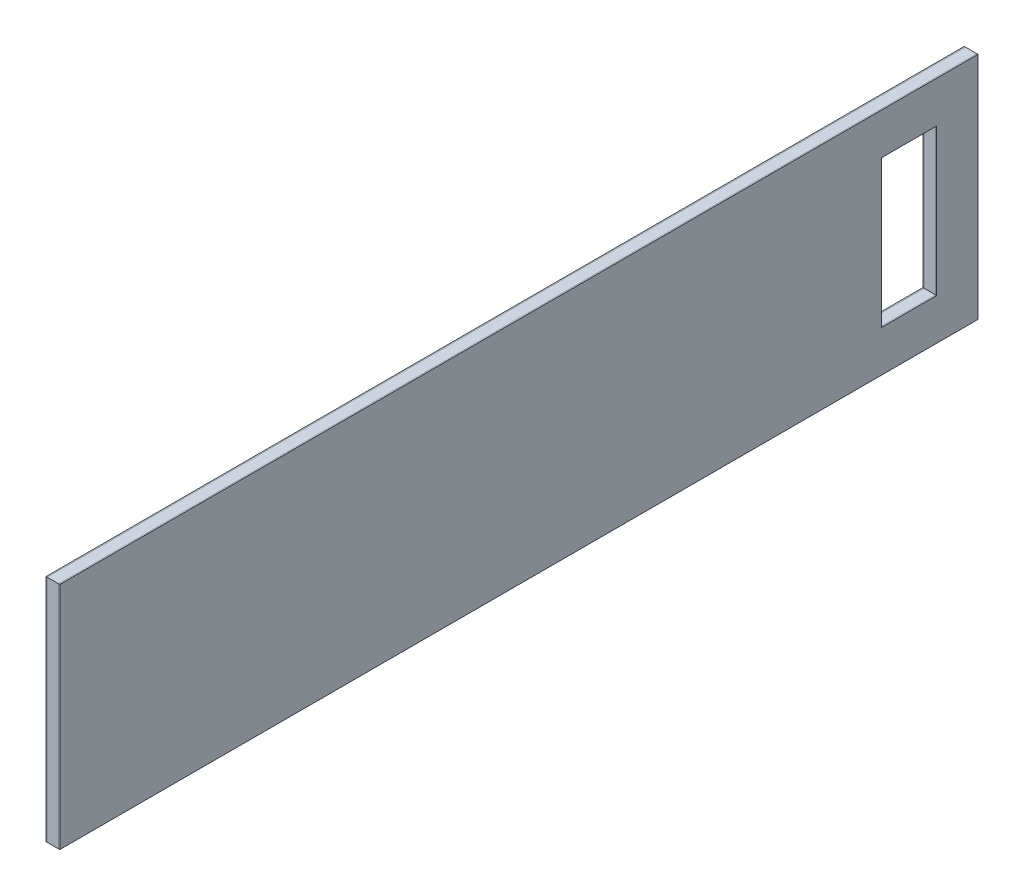
from build123d import *

# Parameters (mm, degrees)
SKETCH1_W           = 200
SKETCH1_H           = 50
SKETCH1_W_2         = 12
SKETCH1_H_2         = 32
BOSS_EXTRUDE1_DEPTH = 0.25
SKETCH2_W           = 200
SKETCH2_H           = 50
SKETCH2_W_2         = 12
SKETCH2_H_2         = 32
BOSS_EXTRUDE2_DEPTH = 2.5
SKETCH3_W           = 200
SKETCH3_H           = 50
SKETCH3_W_2         = 12
SKETCH3_H_2         = 32
BOSS_EXTRUDE3_DEPTH = 0.25


with BuildPart() as part:
    # Sketch1 → Boss-Extrude1 (new body)
    with BuildSketch(Plane(origin=(0, 0, 0), x_dir=(0, 0, -1), z_dir=(1, 0, 0))):
        Rectangle(SKETCH1_W, SKETCH1_H)
        with Locations((85, 0)):
            Rectangle(SKETCH1_W_2, SKETCH1_H_2, mode=Mode.SUBTRACT)
    extrude(amount=BOSS_EXTRUDE1_DEPTH)


with BuildPart() as body_2:
    # Sketch2 → Boss-Extrude2 (new body)
    with BuildSketch(Plane.ZY):
        Rectangle(SKETCH2_W, SKETCH2_H)
        with Locations((-85, 0)):
            Rectangle(SKETCH2_W_2, SKETCH2_H_2, mode=Mode.SUBTRACT)
    extrude(amount=BOSS_EXTRUDE2_DEPTH)


with BuildPart() as body_3:
    # Sketch3 → Boss-Extrude3 (new body)
    with BuildSketch(Plane.ZY.offset(2.5)):
        Rectangle(SKETCH3_W, SKETCH3_H)
        with Locations((-85, 0)):
            Rectangle(SKETCH3_W_2, SKETCH3_H_2, mode=Mode.SUBTRACT)
    extrude(amount=BOSS_EXTRUDE3_DEPTH)


solid = Compound([part.part, body_2.part, body_3.part])
